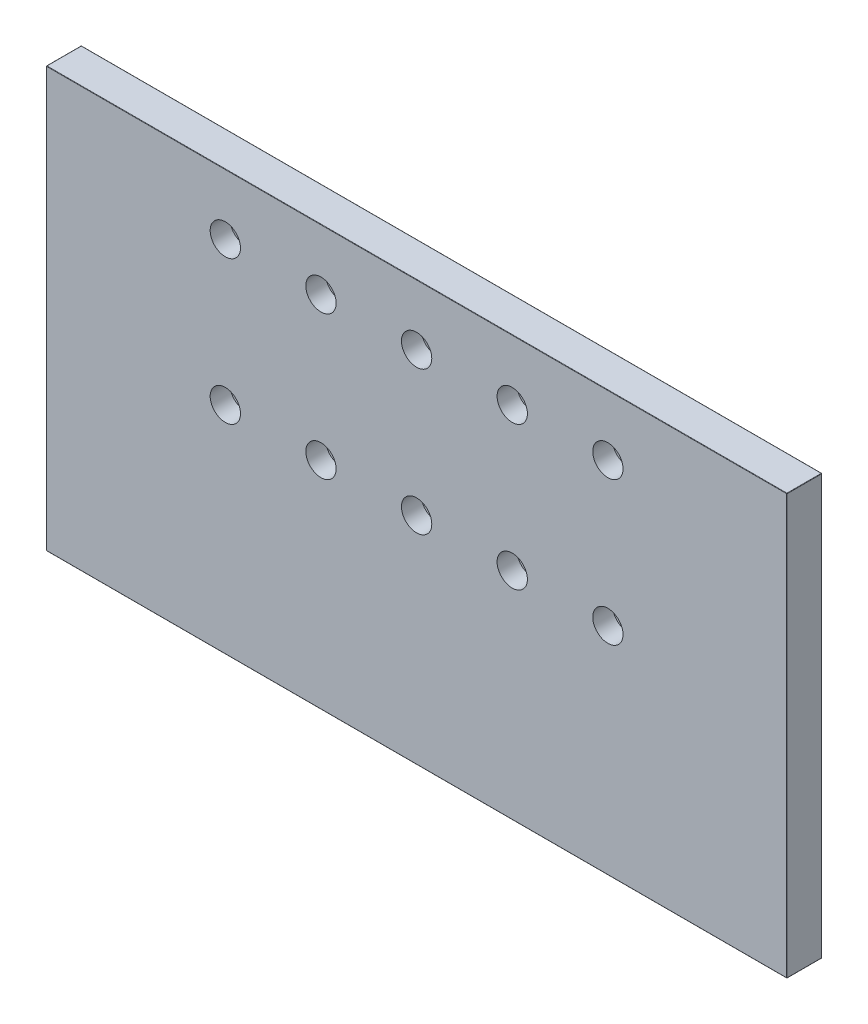
from build123d import *

# Parameters (mm, degrees)
SKETCH2_W            = 635
SKETCH2_H            = 360
BOSS_EXTRUDE1_DEPTH  = 30
SKETCH3_R            = 13
CUT_EXTRUDE2_DEPTH   = 17
SKETCH4_R            = 8
CUT_EXTRUDE3_DEPTH   = 14
LPATTERN1_COUNT      = 5
LPATTERN1_PITCH      = 82
LPATTERN1_COUNT_DIR2 = 2
LPATTERN1_PITCH_DIR2 = 123
FILLET1_R            = 0.3
SKETCH7_R            = 5
CUT_EXTRUDE4_DEPTH   = 18
LPATTERN2_COUNT      = 10
LPATTERN2_PITCH      = 68.3


with BuildPart() as part:
    # Sketch2 → Boss-Extrude1 (new body)
    with BuildSketch(Plane.XY):
        with Locations((317.5, 180)):
            Rectangle(SKETCH2_W, SKETCH2_H)
    extrude(amount=BOSS_EXTRUDE1_DEPTH)

    # Sketch3 → Cut-Extrude2 (cut)
    with BuildSketch(Plane.XY.offset(30)):
        with Locations((153.5, 308)):
            Circle(SKETCH3_R)
    cut_extrude2 = extrude(amount=-CUT_EXTRUDE2_DEPTH, mode=Mode.SUBTRACT)

    # Sketch4 → Cut-Extrude3 (cut, through all)
    with BuildSketch(Plane.XY.offset(13)):
        with Locations((153.5, 308)):
            Circle(SKETCH4_R)
    cut_extrude3 = extrude(amount=-CUT_EXTRUDE3_DEPTH, mode=Mode.SUBTRACT)

    # LPattern1: Cut-Extrude2, Cut-Extrude3 5 × 2
    with Locations(*[(i * LPATTERN1_PITCH, -j * LPATTERN1_PITCH_DIR2, 0) for i in range(LPATTERN1_COUNT) for j in range(LPATTERN1_COUNT_DIR2) if (i, j) != (0, 0)]):
        add(cut_extrude2, mode=Mode.SUBTRACT)
        add(cut_extrude3, mode=Mode.SUBTRACT)

    # Fillet1
    fillet1_edges = [part.edges().sort_by_distance(p)[0] for p in [
        (635, 180, 30),
        (317.5, 360, 30),
        (317.5, 360, 0),
        (635, 180, 0),
        (317.5, 0, 0),
        (0, 180, 0),
        (0, 360, 15),
        (635, 360, 15),
        (635, 0, 15),
        (0, 0, 15),
        (317.5, 0, 30),
    ]]
    fillet(fillet1_edges, radius=FILLET1_R)

    # Sketch7 → Cut-Extrude4 (cut)
    with BuildSketch(Plane.XZ):
        with Locations((10, 20)):
            Circle(SKETCH7_R)
    cut_extrude4 = extrude(amount=-CUT_EXTRUDE4_DEPTH, mode=Mode.SUBTRACT)

    # LPattern2: Cut-Extrude4 ×10
    with Locations(*[(i * LPATTERN2_PITCH, 0, 0) for i in range(1, LPATTERN2_COUNT)]):
        add(cut_extrude4, mode=Mode.SUBTRACT)


solid = part.part
